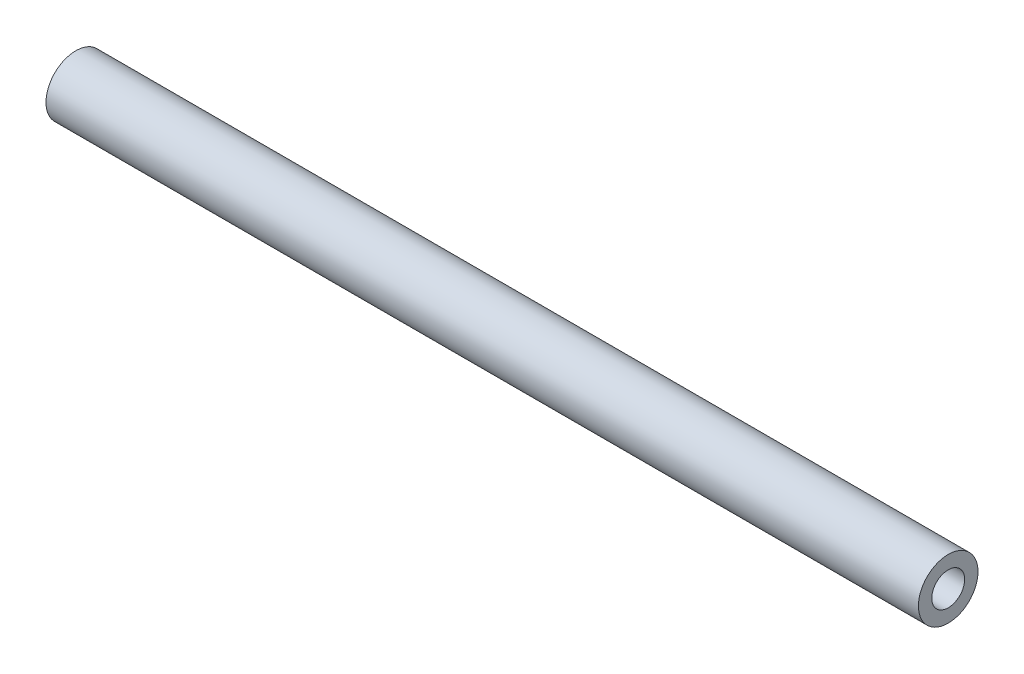
from build123d import *

# Parameters (mm, degrees)
CROQUIS1_R              = 1.5875
CROQUIS1_R_2            = 0.8763
SALIENTE_EXTRUIR1_DEPTH = 45.212
CROQUIS2_R              = 1.5875
CROQUIS2_R_2            = 0.8763
SALIENTE_EXTRUIR2_DEPTH = 1.27


with BuildPart() as part:
    # Croquis1 → Saliente-Extruir1 (new body)
    with BuildSketch(Plane(origin=(0, 0, 0), x_dir=(0, 0, -1), z_dir=(1, 0, 0))):
        Circle(CROQUIS1_R)
        Circle(CROQUIS1_R_2, mode=Mode.SUBTRACT)
    extrude(amount=SALIENTE_EXTRUIR1_DEPTH)

    # Croquis2 → Saliente-Extruir2 (add)
    with BuildSketch(Plane.ZY):
        Circle(CROQUIS2_R)
        Circle(CROQUIS2_R_2, mode=Mode.SUBTRACT)
    extrude(amount=SALIENTE_EXTRUIR2_DEPTH)


solid = part.part
